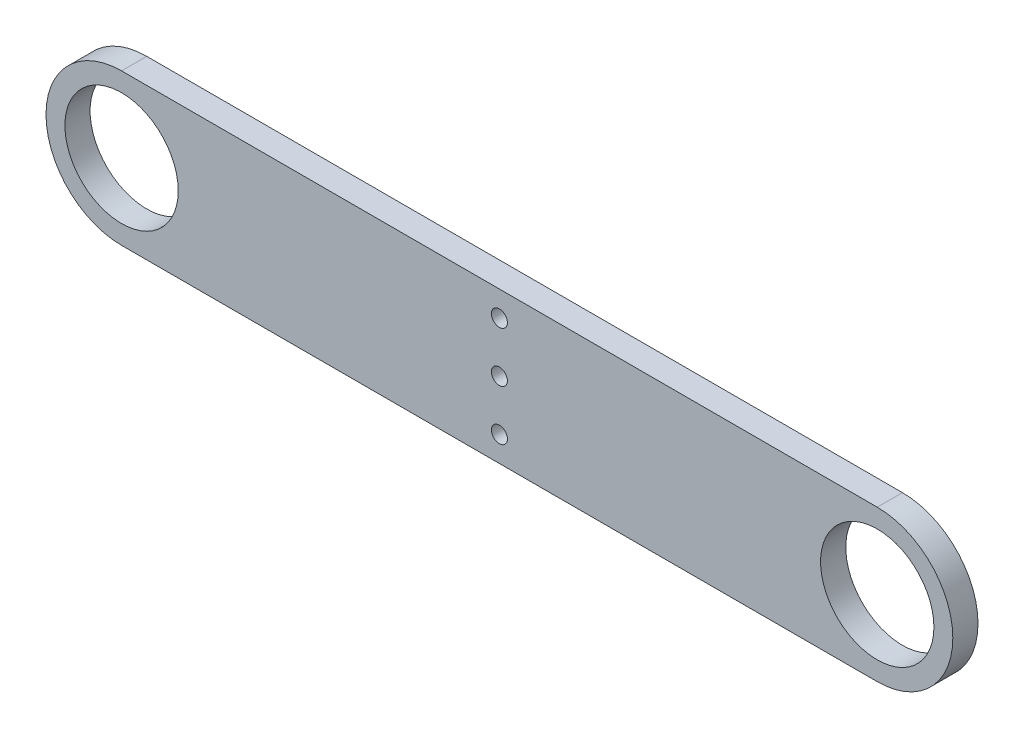
from build123d import *

# Parameters (mm, degrees)
SKETCH1_R           = 14.2875
SKETCH1_R_2         = 2.0193
BOSS_EXTRUDE1_DEPTH = 6.35


with BuildPart() as part:
    # Sketch1 → Boss-Extrude1 (new body)
    with BuildSketch(Plane.XY):
        with BuildLine():
            Line((-95.25, 19.05), (95.25, 19.05))
            ThreePointArc((95.25, 19.05), (114.3, 0), (95.25, -19.05))
            Line((95.25, -19.05), (-95.25, -19.05))
            ThreePointArc((-95.25, -19.05), (-114.3, 0), (-95.25, 19.05))
        make_face()
        with Locations((-95.25, 0)):
            Circle(SKETCH1_R, mode=Mode.SUBTRACT)
        with Locations((95.25, 0)):
            Circle(SKETCH1_R, mode=Mode.SUBTRACT)
        with Locations((0, 12.7)):
            Circle(SKETCH1_R_2, mode=Mode.SUBTRACT)
        Circle(SKETCH1_R_2, mode=Mode.SUBTRACT)
        with Locations((0, -12.7)):
            Circle(SKETCH1_R_2, mode=Mode.SUBTRACT)
    extrude(amount=BOSS_EXTRUDE1_DEPTH)


solid = part.part
